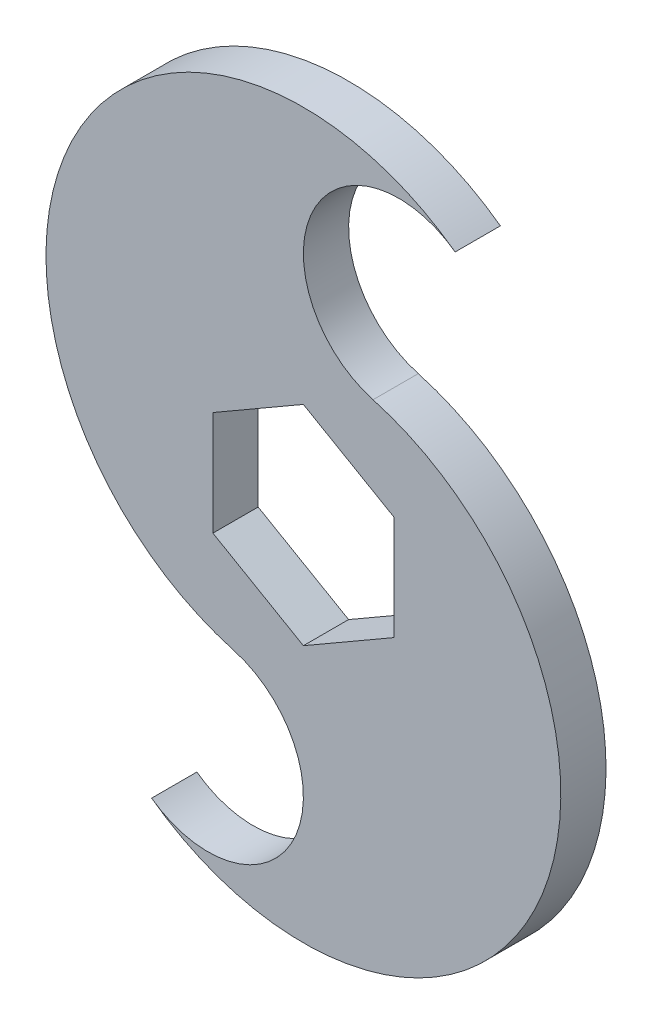
from build123d import *

# Parameters (mm, degrees)
BOSS_EXTRUDE2_DEPTH = 3.175


with BuildPart() as part:
    # Sketch1 → Boss-Extrude2 (new body, symmetric)
    with BuildSketch(Plane.XY):
        with BuildLine():
            ThreePointArc((-21.30491262, -43.851351885), (32.502343983, -30.45576299), (9.776598146, 20.122919685))
            ThreePointArc((9.776598146, 20.122919685), (1.347485848, 38.882849469), (21.30491262, 43.851351885))
            ThreePointArc((21.30491262, 43.851351885), (-32.502343983, 30.45576299), (-9.776598146, -20.122919685))
            ThreePointArc((-9.776598146, -20.122919685), (-1.347485848, -38.882849469), (-21.30491262, -43.851351885))
        make_face()
        Polygon((0, 14.664696837), (-12.7, 7.332348419), (-12.7, -7.332348419), (0, -14.664696837), (12.7, -7.332348419), (12.7, 7.332348419), align=None, mode=Mode.SUBTRACT)
    extrude(amount=BOSS_EXTRUDE2_DEPTH, both=True)


solid = part.part
